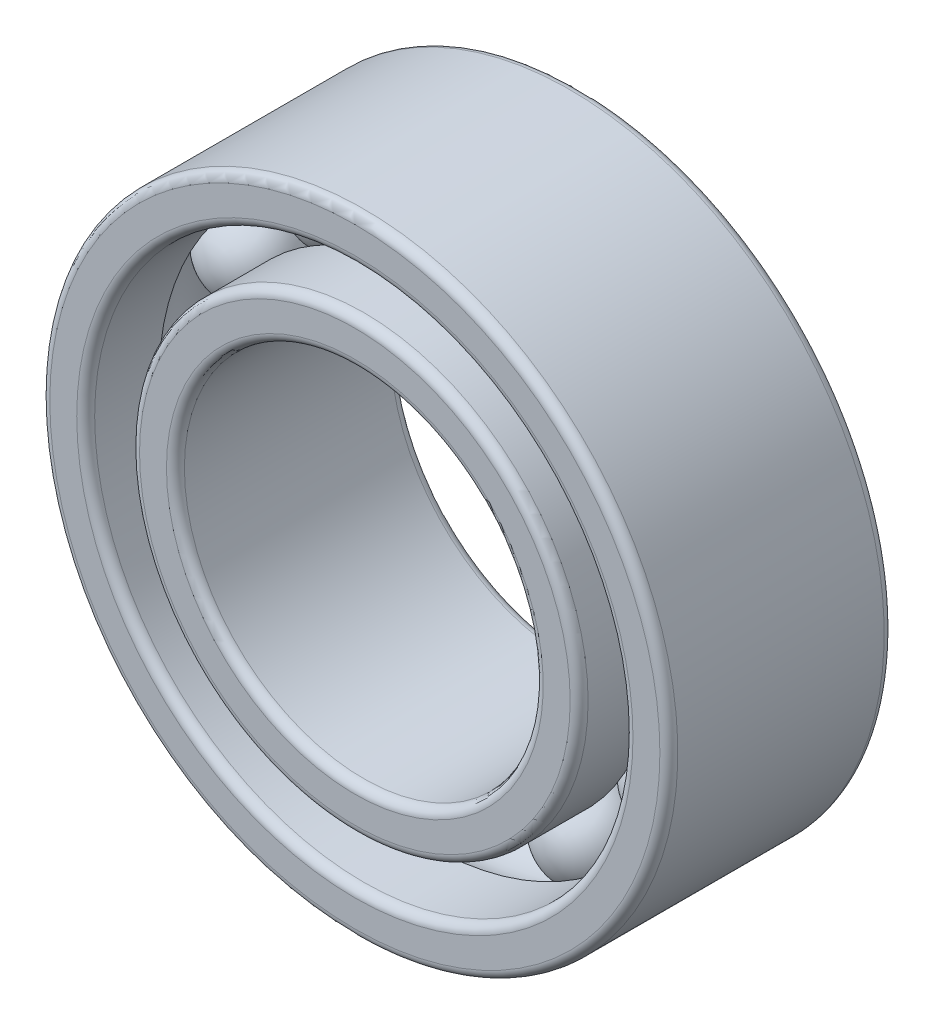
from build123d import *

# Parameters (mm, degrees)
KREISMUSTER4_COUNT = 12
VERRUNDUNG1_R      = 0.1
VERRUNDUNG2_R      = 0.1


with BuildPart() as part:
    # Skizze1 → Rotation1 (revolve)
    with BuildSketch(Plane(origin=(0, 0, 0), x_dir=(0, 0, -1), z_dir=(1, 0, 0))):
        with BuildLine():
            Line((1.25, 3.5), (-1.25, 3.5))
            Line((-1.25, 3.5), (-1.25, 3))
            Line((-1.25, 3), (-0.433012702, 3))
            ThreePointArc((-0.433012702, 3), (0, 3.25), (0.433012702, 3))
            Line((0.433012702, 3), (1.25, 3))
            Line((1.25, 3), (1.25, 3.5))
        make_face()
        with BuildLine():
            ThreePointArc((0.433012702, 2.5), (0, 2.25), (-0.433012702, 2.5))
            Line((-0.433012702, 2.5), (-1.25, 2.5))
            Line((-1.25, 2.5), (-1.25, 2))
            Line((-1.25, 2), (1.25, 2))
            Line((1.25, 2), (1.25, 2.5))
            Line((1.25, 2.5), (0.433012702, 2.5))
        make_face()
    revolve(axis=Axis((0, 0, 0), (0, 0, -1)))

    # Verrundung1
    verrundung1_edges = [part.edges().sort_by_distance(p)[0] for p in [
        (0, -3, -1.25),
        (0, -3, 1.25),
        (0, -3.5, -1.25),
        (0, -3.5, 1.25),
    ]]
    fillet(verrundung1_edges, radius=VERRUNDUNG1_R)

    # Verrundung2
    verrundung2_edges = [part.edges().sort_by_distance(p)[0] for p in [
        (0, -2.5, -1.25),
        (0, -2, -1.25),
        (0, -2.5, 1.25),
        (0, -2, 1.25),
    ]]
    fillet(verrundung2_edges, radius=VERRUNDUNG2_R)


with BuildPart() as body_2:
    # Skizze1_5 → Rotation3 (revolve)
    with BuildSketch(Plane(origin=(0, 0, 0), x_dir=(0, 0, -1), z_dir=(1, 0, 0))):
        with BuildLine():
            ThreePointArc((0.433012702, 3), (0, 3.25), (-0.433012702, 3))
            ThreePointArc((-0.433012702, 3), (-0.482962913, 2.879409523), (-0.5, 2.75))
            Line((-0.5, 2.75), (0.5, 2.75))
            ThreePointArc((0.5, 2.75), (0.482962913, 2.879409523), (0.433012702, 3))
        make_face()
    revolve(axis=Axis((0, 2.75, 0.5), (0, 0, -1)))


with BuildPart() as kreismuster4_1:
    # Kreismuster4: pattern copy
    add(body_2.part.rotate(Axis((0, 0, -1.25), (0, 0, 1)), 1 * 360 / KREISMUSTER4_COUNT))


with BuildPart() as kreismuster4_2:
    # Kreismuster4: pattern copy
    add(body_2.part.rotate(Axis((0, 0, -1.25), (0, 0, 1)), 2 * 360 / KREISMUSTER4_COUNT))


with BuildPart() as kreismuster4_3:
    # Kreismuster4: pattern copy
    add(body_2.part.rotate(Axis((0, 0, -1.25), (0, 0, 1)), 3 * 360 / KREISMUSTER4_COUNT))


with BuildPart() as kreismuster4_4:
    # Kreismuster4: pattern copy
    add(body_2.part.rotate(Axis((0, 0, -1.25), (0, 0, 1)), 4 * 360 / KREISMUSTER4_COUNT))


with BuildPart() as kreismuster4_5:
    # Kreismuster4: pattern copy
    add(body_2.part.rotate(Axis((0, 0, -1.25), (0, 0, 1)), 5 * 360 / KREISMUSTER4_COUNT))


with BuildPart() as kreismuster4_6:
    # Kreismuster4: pattern copy
    add(body_2.part.rotate(Axis((0, 0, -1.25), (0, 0, 1)), 6 * 360 / KREISMUSTER4_COUNT))


with BuildPart() as kreismuster4_7:
    # Kreismuster4: pattern copy
    add(body_2.part.rotate(Axis((0, 0, -1.25), (0, 0, 1)), 7 * 360 / KREISMUSTER4_COUNT))


with BuildPart() as kreismuster4_8:
    # Kreismuster4: pattern copy
    add(body_2.part.rotate(Axis((0, 0, -1.25), (0, 0, 1)), 8 * 360 / KREISMUSTER4_COUNT))


with BuildPart() as kreismuster4_9:
    # Kreismuster4: pattern copy
    add(body_2.part.rotate(Axis((0, 0, -1.25), (0, 0, 1)), 9 * 360 / KREISMUSTER4_COUNT))


with BuildPart() as kreismuster4_10:
    # Kreismuster4: pattern copy
    add(body_2.part.rotate(Axis((0, 0, -1.25), (0, 0, 1)), 10 * 360 / KREISMUSTER4_COUNT))


with BuildPart() as kreismuster4_11:
    # Kreismuster4: pattern copy
    add(body_2.part.rotate(Axis((0, 0, -1.25), (0, 0, 1)), 11 * 360 / KREISMUSTER4_COUNT))


solid = Compound([part.part, body_2.part, kreismuster4_1.part, kreismuster4_2.part, kreismuster4_3.part, kreismuster4_4.part, kreismuster4_5.part, kreismuster4_6.part, kreismuster4_7.part, kreismuster4_8.part, kreismuster4_9.part, kreismuster4_10.part, kreismuster4_11.part])
